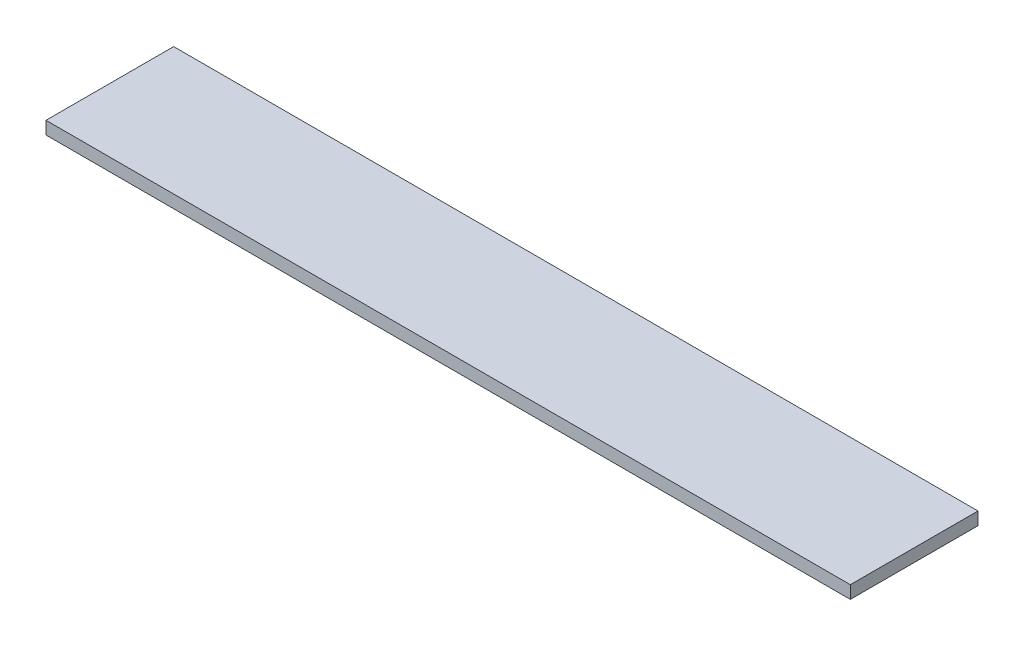
from build123d import *

# Parameters (mm, degrees)
SKETCH1_W           = 80.01
SKETCH1_H           = 12.7
BOSS_EXTRUDE1_DEPTH = 1.27


with BuildPart() as part:
    # Sketch1 → Boss-Extrude1 (new body)
    with BuildSketch(Plane(origin=(0, 0, 0), x_dir=(1, 0, 0), z_dir=(0, 1, 0))):
        Rectangle(SKETCH1_W, SKETCH1_H)
    extrude(amount=BOSS_EXTRUDE1_DEPTH)


solid = part.part
